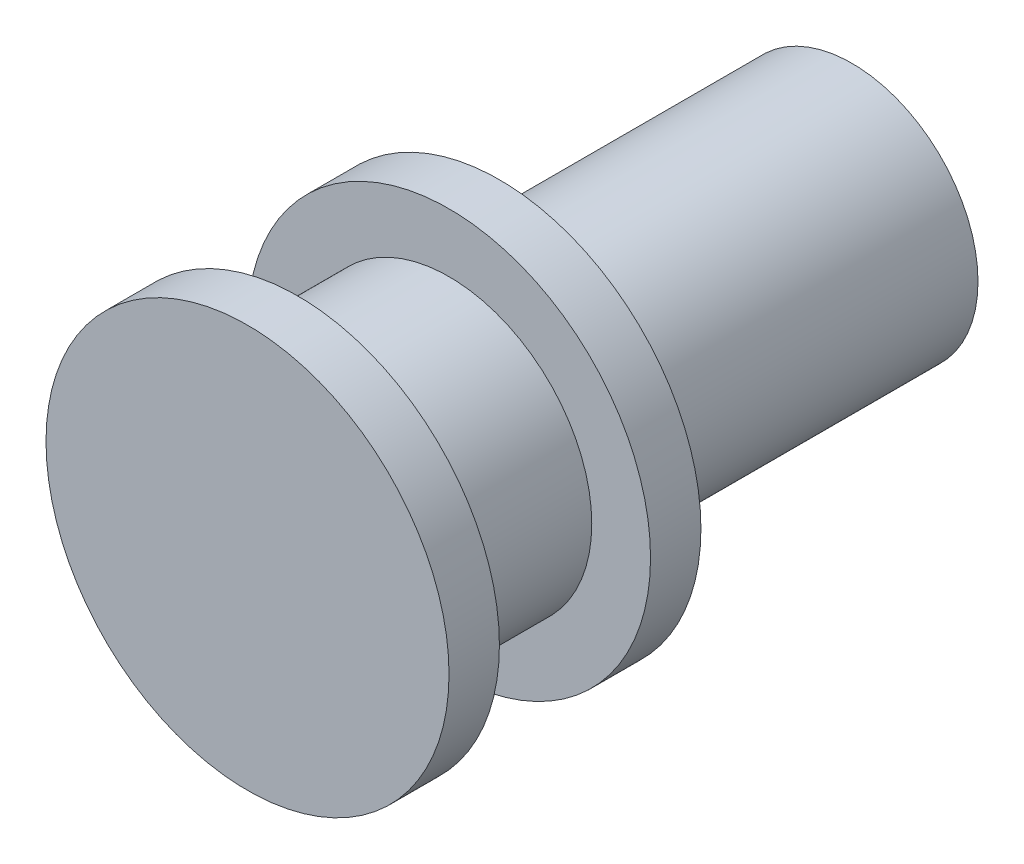
from build123d import *


with BuildPart() as part:
    # Sketch2 → Revolve1 (revolve)
    with BuildSketch(Plane(origin=(0, 0, 0), x_dir=(0, 0, -1), z_dir=(1, 0, 0))):
        Polygon((0, 0), (0, 3.048), (0.762, 3.048), (0.762, 2.159), (3.048, 2.159), (3.048, 3.048), (3.81, 3.048), (3.81, 1.905), (9.144, 1.905), (9.144, 0), align=None)
    revolve(axis=Axis((0, 0, 2.450945122), (0, 0, -1)))


solid = part.part
